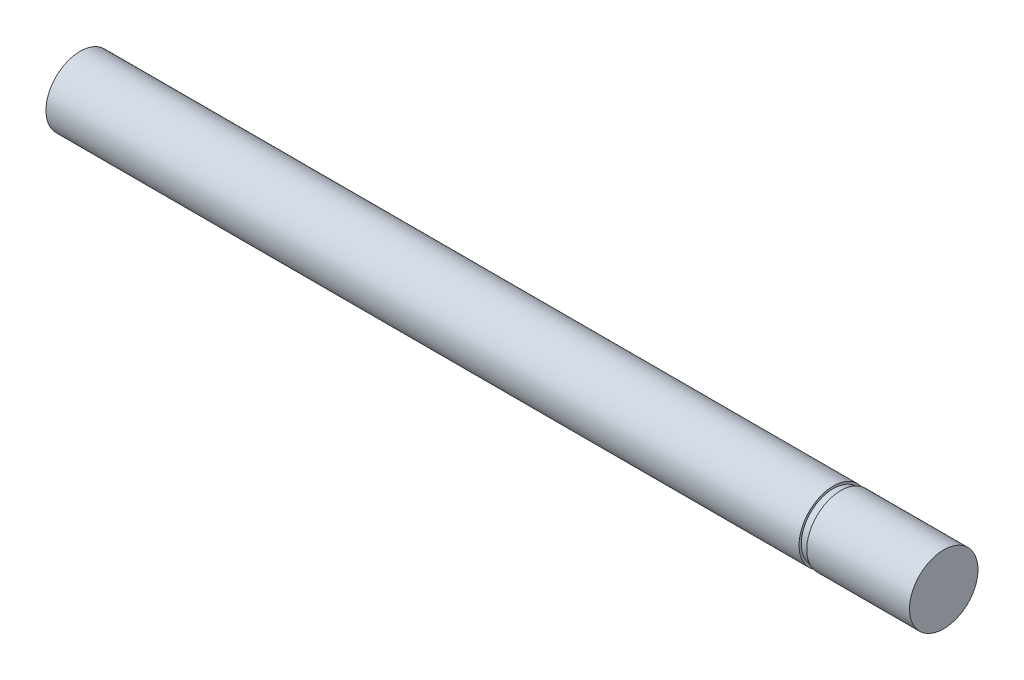
from build123d import *

# Parameters (mm, degrees)
SKETCH1_R                   = 6.35
BOSS_EXTRUDE1_DEPTH         = 69.7992
SKETCH2_W                   = 1.4224
SKETCH2_H                   = 5.9436
SKETCH3_R                   = 6.35
BOSS_EXTRUDE2_DEPTH         = 19.05
F_1_4_20_TAPPED_HOLE1_D     = 5.1054
F_1_4_20_TAPPED_HOLE1_DEPTH = 16.51
F_1_4_20_TAPPED_HOLE1_TIP   = 1.533816902


with BuildPart() as part:
    # Sketch1 → Boss-Extrude1 (new body, symmetric)
    with BuildSketch(Plane(origin=(0, 0, 0), x_dir=(0, 0, -1), z_dir=(1, 0, 0))):
        Circle(SKETCH1_R)
    extrude(amount=BOSS_EXTRUDE1_DEPTH, both=True)

    # Sketch2 → Revolve2 (revolve)
    with BuildSketch(Plane.XY):
        with Locations((70.5104, 2.9718)):
            Rectangle(SKETCH2_W, SKETCH2_H)
    revolve(axis=Axis((0, 0, 0), (1, 0, 0)))

    # Sketch3 → Boss-Extrude2 (add)
    with BuildSketch(Plane(origin=(71.2216, 0, 0), x_dir=(0, 0, -1), z_dir=(1, 0, 0))):
        Circle(SKETCH3_R)
    extrude(amount=BOSS_EXTRUDE2_DEPTH)

    # 1/4-20 Tapped Hole1
    with Locations(Plane.ZY.offset(69.7992)):
        with Locations((0, 0)):
            Hole(F_1_4_20_TAPPED_HOLE1_D / 2, depth=F_1_4_20_TAPPED_HOLE1_DEPTH)
            with Locations((0, 0, -(F_1_4_20_TAPPED_HOLE1_DEPTH + F_1_4_20_TAPPED_HOLE1_TIP / 2))):  # 118° drill point
                Cone(0, F_1_4_20_TAPPED_HOLE1_D / 2, F_1_4_20_TAPPED_HOLE1_TIP, mode=Mode.SUBTRACT)


solid = part.part
